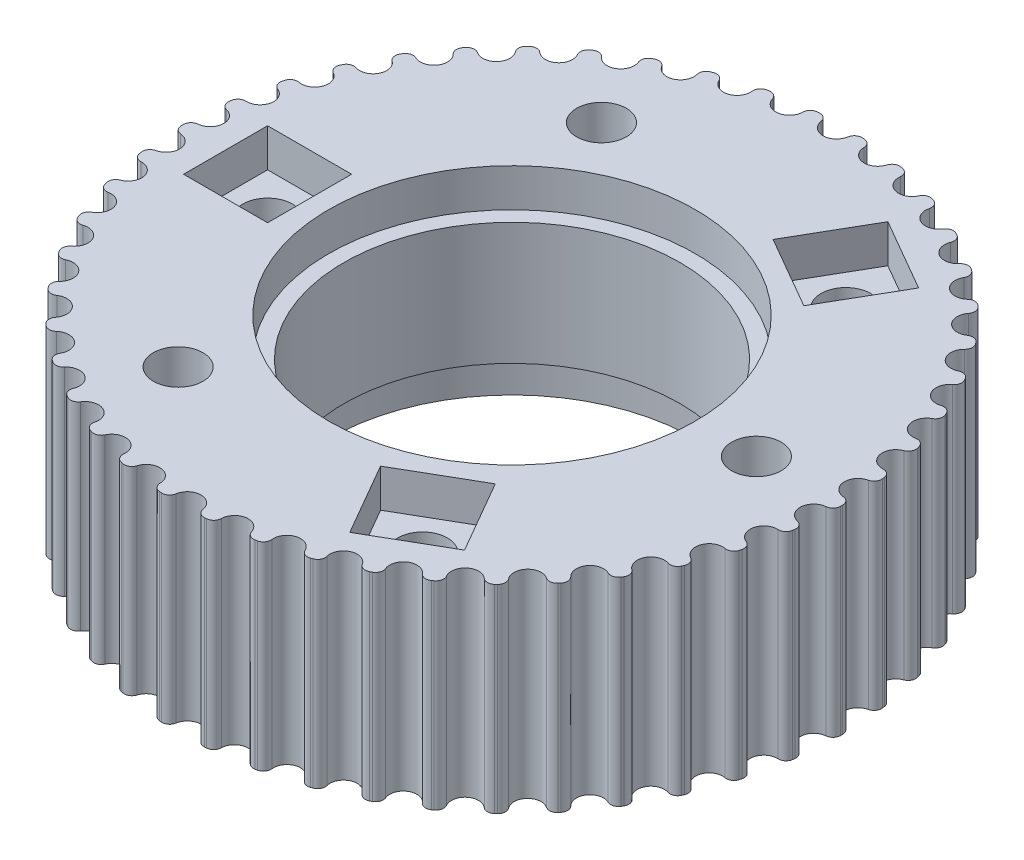
from build123d import *

# Parameters (mm, degrees)
BOSS_EXTRUDE1_DEPTH     = 6.499999954
CIRPATTERN1_COUNT       = 46
CUT_EXTRUDE1_DEPTH      = 32.175108964
CUT_EXTRUDE1_DEPTH_BACK = 32.175108964
SKETCH3_R               = 10.999999971
SKETCH4_R               = 1.625
CUT_EXTRUDE2_DEPTH      = 32.175108964
CIRPATTERN2_COUNT       = 6
CUT_EXTRUDE3_START      = 4.000000128
SKETCH7_R               = 12.000000003
CUT_EXTRUDE3_DEPTH      = 28.175108836
SKETCH8_W               = 5.5
SKETCH8_H               = 5.5
CUT_EXTRUDE4_DEPTH      = 2.5
SKETCH9_W               = 5.5
SKETCH9_H               = 5.5
CUT_EXTRUDE5_DEPTH      = 2.5
CIRPATTERN3_COUNT       = 3


with BuildPart() as part:
    # Sketch1 → Boss-Extrude1 (new, symmetric)
    with BuildSketch(Plane(origin=(0, 0, 0), x_dir=(1, 0, 0), z_dir=(0, 1, 0))):
        with BuildLine():
            ThreePointArc((0.879311396, 21.114512434), (0.578665758, 20.57583177), (0, 20.3620314))
            ThreePointArc((0, 20.3620314), (-1.389554164, -20.314562805), (2.772629585, 20.172378341))
            ThreePointArc((2.772629585, 20.172378341), (2.228466031, 20.46298234), (2.003970963, 21.037583612))
            ThreePointArc((2.003970963, 21.037583612), (1.866829754, 21.372398068), (1.539728474, 21.527036951))
            ThreePointArc((1.539728474, 21.527036951), (1.472809915, 21.531718803), (1.405877127, 21.536192634))
            ThreePointArc((1.405877127, 21.536192634), (1.060765828, 21.427534351), (0.879311396, 21.114512434))
        make_face()
    boss_extrude1 = extrude(amount=BOSS_EXTRUDE1_DEPTH, both=True)

    # CirPattern1: Boss-Extrude1 ×46 about axis
    cirpattern1_axis = Axis((0, 3.3, 0), (0, -1, 0))
    for i in range(1, CIRPATTERN1_COUNT):
        add(boss_extrude1.rotate(cirpattern1_axis, i * 360 / CIRPATTERN1_COUNT))

    # Sketch3 → Cut-Extrude1 (cut, two sides: drawn at the far end of the back side and taken through both)
    with BuildSketch(Plane(origin=(0, 0, 0), x_dir=(-1, 0, 0), z_dir=(0, -1, 0)).offset(-CUT_EXTRUDE1_DEPTH_BACK)):
        Circle(SKETCH3_R)
    extrude(amount=CUT_EXTRUDE1_DEPTH + CUT_EXTRUDE1_DEPTH_BACK, mode=Mode.SUBTRACT)

    # Sketch4 → Cut-Extrude2 (cut, symmetric)
    with BuildSketch(Plane(origin=(0, 0, 0), x_dir=(1, 0, 0), z_dir=(0, 1, 0))):
        with Locations((-16.000000004, 0)):
            Circle(SKETCH4_R)
    cut_extrude2 = extrude(amount=CUT_EXTRUDE2_DEPTH, both=True, mode=Mode.SUBTRACT)

    # CirPattern2: Cut-Extrude2 ×6 about axis
    cirpattern2_axis = Axis((0, 6.499999954, 0), (0, -1, 0))
    for i in range(1, CIRPATTERN2_COUNT):
        add(cut_extrude2.rotate(cirpattern2_axis, i * 360 / CIRPATTERN2_COUNT), mode=Mode.SUBTRACT)

    # Sketch7 → Cut-Extrude3 (cut, through all)
    with BuildSketch(Plane(origin=(0, 0, 0), x_dir=(1, 0, 0), z_dir=(0, 1, 0)).offset(CUT_EXTRUDE3_START)):
        Circle(SKETCH7_R)
    cut_extrude3 = extrude(amount=CUT_EXTRUDE3_DEPTH, mode=Mode.SUBTRACT)

    # Mirror2: Cut-Extrude3 across plane
    add(cut_extrude3.mirror(Plane.ZX), mode=Mode.SUBTRACT)

    # Sketch8 → Cut-Extrude4 (cut)
    with BuildSketch(Plane.XZ.offset(6.499999954)):
        with Locations((16.000000004, 0)):
            Rectangle(SKETCH8_W, SKETCH8_H)
    cut_extrude4 = extrude(amount=-CUT_EXTRUDE4_DEPTH, mode=Mode.SUBTRACT)

    # Sketch9 → Cut-Extrude5 (cut)
    with BuildSketch(Plane(origin=(0, 6.499999954, 0), x_dir=(1, 0, 0), z_dir=(0, 1, 0))):
        with Locations((-16.000000004, 0)):
            Rectangle(SKETCH9_W, SKETCH9_H)
    cut_extrude5 = extrude(amount=-CUT_EXTRUDE5_DEPTH, mode=Mode.SUBTRACT)

    # CirPattern3: Cut-Extrude4, Cut-Extrude5 ×3 about axis
    cirpattern3_axis = Axis((0, 3.3, 0), (0, -1, 0))
    add([cut_extrude4.rotate(cirpattern3_axis, i * 360 / CIRPATTERN3_COUNT) for i in range(1, CIRPATTERN3_COUNT)], mode=Mode.SUBTRACT)
    add([cut_extrude5.rotate(cirpattern3_axis, i * 360 / CIRPATTERN3_COUNT) for i in range(1, CIRPATTERN3_COUNT)], mode=Mode.SUBTRACT)


solid = part.part
